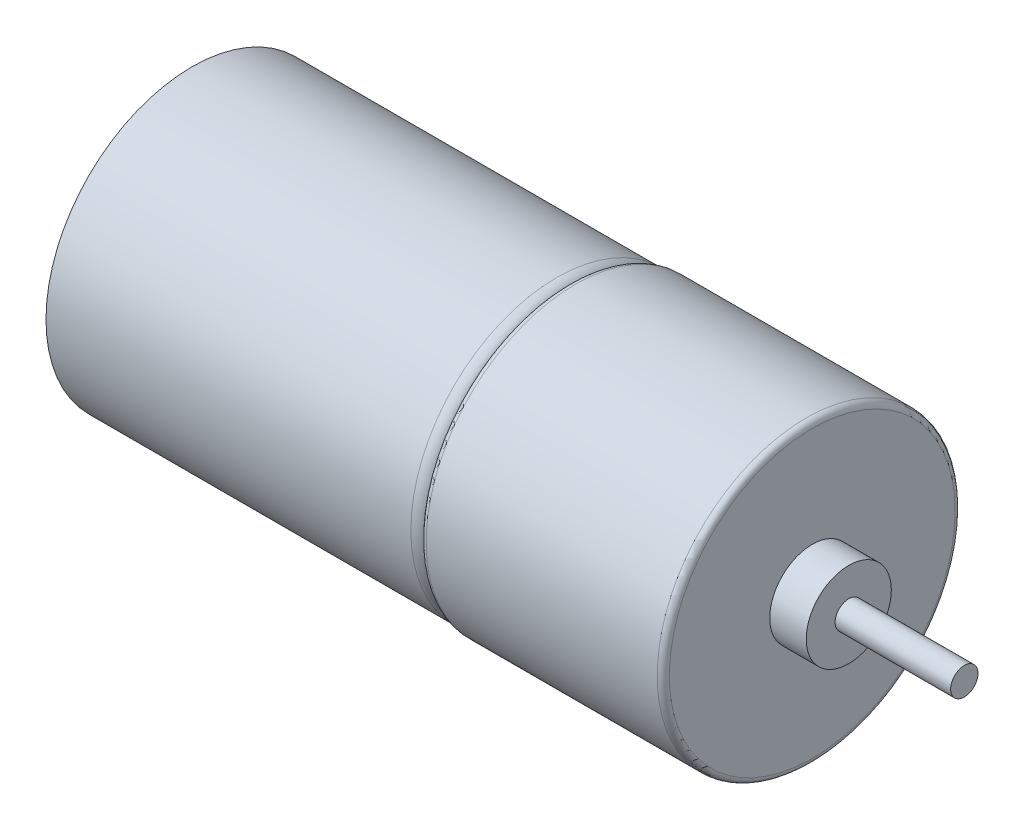
from build123d import *

# Parameters (mm, degrees)
SKETCH1_R           = 12
BOSS_EXTRUDE1_DEPTH = 31
FILLET1_R           = 1
SKETCH2_R           = 11.5
CUT_EXTRUDE1_DEPTH  = 1
SKETCH3_R           = 12.25
BOSS_EXTRUDE2_DEPTH = 20
FILLET2_R           = 0.5
SKETCH4_R           = 3.5
BOSS_EXTRUDE3_DEPTH = 3
SKETCH5_R           = 1.125510402
BOSS_EXTRUDE4_DEPTH = 9.5


with BuildPart() as part:
    # Sketch1 → Boss-Extrude1 (new body)
    with BuildSketch(Plane(origin=(0, 0, 0), x_dir=(0, 0, -1), z_dir=(1, 0, 0))):
        Circle(SKETCH1_R)
    extrude(amount=BOSS_EXTRUDE1_DEPTH)

    # Fillet1
    fillet1_edges = [part.edges().sort_by_distance(p)[0] for p in [
        (31, 0, 12),
    ]]
    fillet(fillet1_edges, radius=FILLET1_R)

    # Sketch2 → Cut-Extrude1 (cut)
    with BuildSketch(Plane.ZY):
        Circle(SKETCH2_R)
    extrude(amount=-CUT_EXTRUDE1_DEPTH, mode=Mode.SUBTRACT)

    # Sketch3 → Boss-Extrude2 (add)
    with BuildSketch(Plane(origin=(31, 0, 0), x_dir=(0, 0, -1), z_dir=(1, 0, 0))):
        Circle(SKETCH3_R)
    extrude(amount=BOSS_EXTRUDE2_DEPTH)

    # Fillet2
    fillet2_edges = [part.edges().sort_by_distance(p)[0] for p in [
        (31, 0, 12.25),
        (51, 0, 12.25),
    ]]
    fillet(fillet2_edges, radius=FILLET2_R)

    # Sketch4 → Boss-Extrude3 (add)
    with BuildSketch(Plane(origin=(51, 0, 0), x_dir=(0, 0, -1), z_dir=(1, 0, 0))):
        Circle(SKETCH4_R)
    extrude(amount=BOSS_EXTRUDE3_DEPTH)

    # Sketch5 → Boss-Extrude4 (add)
    with BuildSketch(Plane(origin=(54, 0, 0), x_dir=(0, 0, -1), z_dir=(1, 0, 0))):
        Circle(SKETCH5_R)
    extrude(amount=BOSS_EXTRUDE4_DEPTH)


solid = part.part
